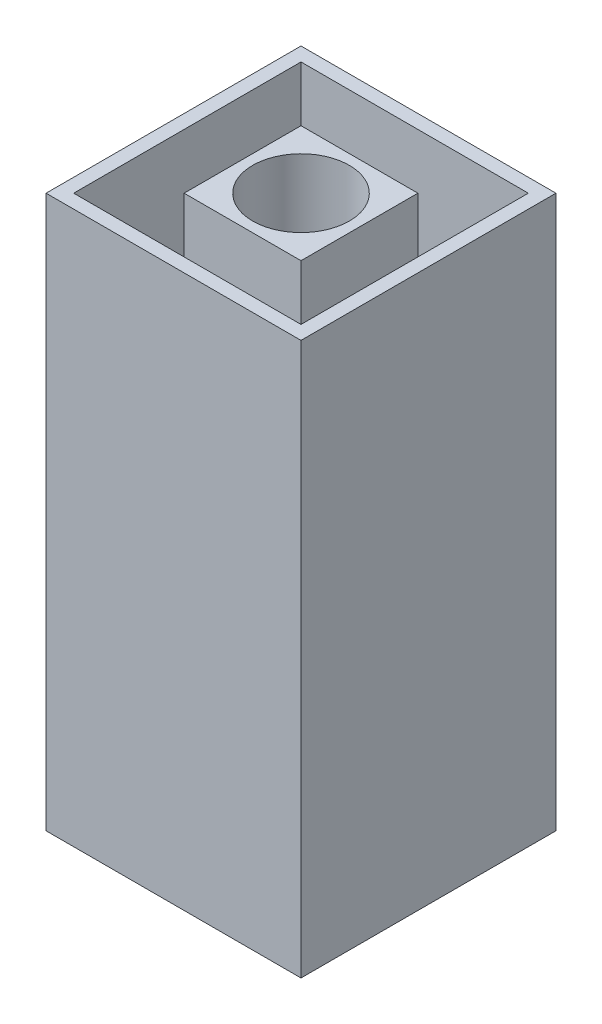
from build123d import *

# Parameters (mm, degrees)
SKETCH1_W           = 2.77
SKETCH1_H           = 2.77
BOSS_EXTRUDE1_DEPTH = 6
SKETCH2_R           = 0.525
CUT_EXTRUDE1_DEPTH  = 7
SKETCH3_W           = 2.47
SKETCH3_H           = 2.47
SKETCH3_W_2         = 1.27
SKETCH3_H_2         = 1.27
CUT_EXTRUDE2_DEPTH  = 10


with BuildPart() as part:
    # Sketch1 → Boss-Extrude1 (new body)
    with BuildSketch(Plane(origin=(0, 0, 0), x_dir=(1, 0, 0), z_dir=(0, 1, 0))):
        Rectangle(SKETCH1_W, SKETCH1_H)
    extrude(amount=BOSS_EXTRUDE1_DEPTH)

    # Sketch2 → Cut-Extrude1 (cut, through all)
    with BuildSketch(Plane(origin=(0, 6, 0), x_dir=(1, 0, 0), z_dir=(0, 1, 0))):
        Circle(SKETCH2_R)
    extrude(amount=-CUT_EXTRUDE1_DEPTH, mode=Mode.SUBTRACT)

    # Sketch3 → Cut-Extrude2 (cut)
    with BuildSketch(Plane(origin=(0, 6, 0), x_dir=(1, 0, 0), z_dir=(0, 1, 0))):
        Rectangle(SKETCH3_W, SKETCH3_H)
        Rectangle(SKETCH3_W_2, SKETCH3_H_2, mode=Mode.SUBTRACT)
    extrude(amount=-CUT_EXTRUDE2_DEPTH, mode=Mode.SUBTRACT)


solid = part.part
